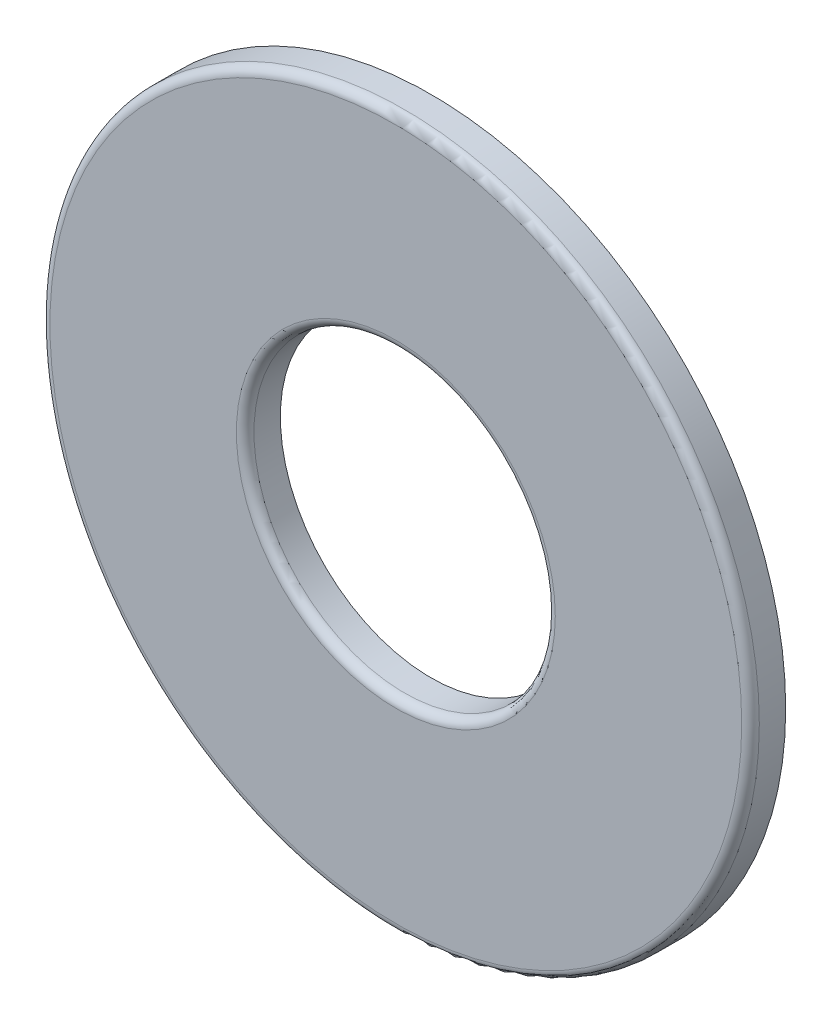
from build123d import *

# Parameters (mm, degrees)
SKETCH3_R                = 15.875
SKETCH3_R_2              = 6.7437
BOSS_EXTRUDE1_DEPTH      = 0.7874
BOSS_EXTRUDE1_DEPTH_BACK = 0.7874
FILLET1_R                = 0.3937


with BuildPart() as part:
    # Sketch3 → Boss-Extrude1 (new body, two sides)
    with BuildSketch(Plane.XY) as boss_extrude1_sk:
        Circle(SKETCH3_R)
        Circle(SKETCH3_R_2, mode=Mode.SUBTRACT)
    extrude(amount=BOSS_EXTRUDE1_DEPTH)
    extrude(boss_extrude1_sk.sketch, amount=-BOSS_EXTRUDE1_DEPTH_BACK)

    # Fillet1
    fillet1_edges = [part.edges().sort_by_distance(p)[0] for p in [
        (-15.875, 0, 0.7874),
        (-6.7437, 0, 0.7874),
    ]]
    fillet(fillet1_edges, radius=FILLET1_R)


solid = part.part
